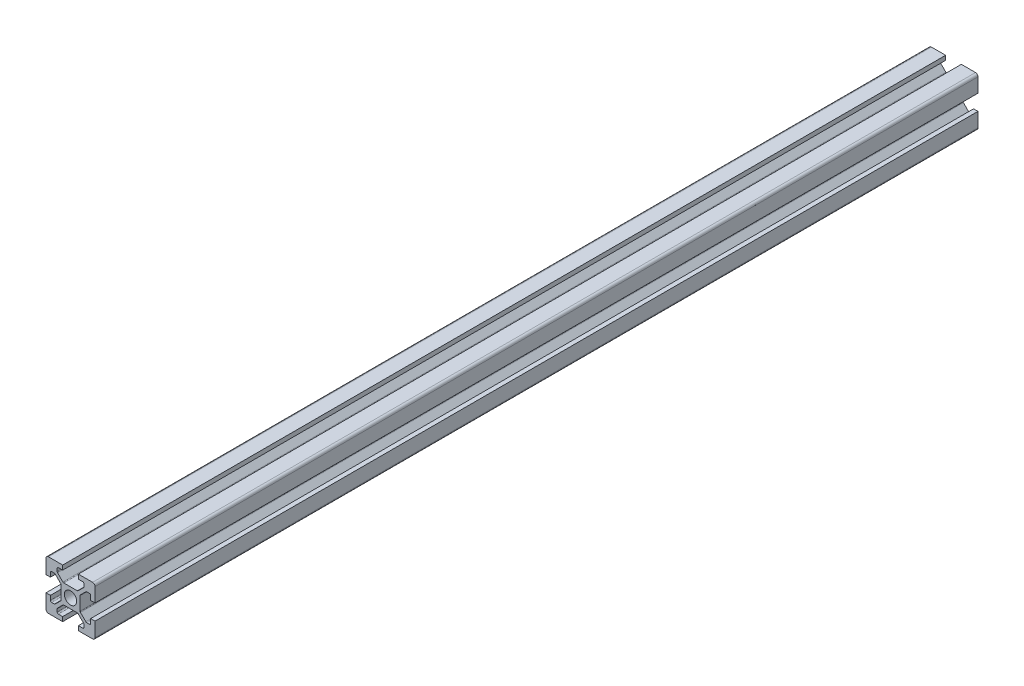
from build123d import *

# Parameters (mm, degrees)
SKETCH1_R           = 2.5
BOSS_EXTRUDE1_DEPTH = 360
FILLET1_R           = 1
FILLET2_R           = 0.5
FILLET3_R           = 0.5
FILLET4_R           = 0.5
FILLET5_R           = 0.5


with BuildPart() as part:
    # Sketch1 → Boss-Extrude1 (new body)
    with BuildSketch(Plane.XY):
        Polygon((13.2, 0), (13.2, 1.8), (15.45, 1.8), (15.45, 3.6), (12.95, 6.1), (7.05, 6.1), (4.55, 3.6), (4.55, 1.8), (6.8, 1.8), (6.8, 0), (0, 0), (0, 6.8), (1.8, 6.8), (1.8, 4.55), (3.6, 4.55), (6.1, 7.05), (6.1, 12.95), (3.6, 15.45), (1.8, 15.45), (1.8, 13.2), (0, 13.2), (0, 20), (6.8, 20), (6.8, 18.2), (4.55, 18.2), (4.55, 16.4), (7.05, 13.9), (12.95, 13.9), (15.45, 16.4), (15.45, 18.2), (13.2, 18.2), (13.2, 20), (20, 20), (20, 13.2), (18.2, 13.2), (18.2, 15.45), (16.4, 15.45), (13.9, 12.95), (13.9, 7.05), (16.4, 4.55), (18.2, 4.55), (18.2, 6.8), (20, 6.8), (20, 0), align=None)
        with Locations((10, 10)):
            Circle(SKETCH1_R, mode=Mode.SUBTRACT)
    extrude(amount=BOSS_EXTRUDE1_DEPTH)

    # Fillet1
    fillet1_edges = [part.edges().sort_by_distance(p)[0] for p in [
        (0, 0, 180),
        (0, 20, 180),
        (20, 20, 180),
        (20, 0, 180),
    ]]
    fillet(fillet1_edges, radius=FILLET1_R)

    # Fillet2
    fillet2_edges = [part.edges().sort_by_distance(p)[0] for p in [
        (4.55, 18.2, 180),
        (4.55, 16.4, 180),
        (7.05, 13.9, 180),
        (12.95, 13.9, 180),
        (15.45, 16.4, 180),
        (15.45, 18.2, 180),
    ]]
    fillet(fillet2_edges, radius=FILLET2_R)

    # Fillet3
    fillet3_edges = [part.edges().sort_by_distance(p)[0] for p in [
        (18.2, 15.45, 180),
        (16.4, 15.45, 180),
        (13.9, 12.95, 180),
        (13.9, 7.05, 180),
        (16.4, 4.55, 180),
        (18.2, 4.55, 180),
    ]]
    fillet(fillet3_edges, radius=FILLET3_R)

    # Fillet4
    fillet4_edges = [part.edges().sort_by_distance(p)[0] for p in [
        (1.8, 4.55, 180),
        (3.6, 4.55, 180),
        (6.1, 7.05, 180),
        (6.1, 12.95, 180),
        (3.6, 15.45, 180),
        (1.8, 15.45, 180),
    ]]
    fillet(fillet4_edges, radius=FILLET4_R)

    # Fillet5
    fillet5_edges = [part.edges().sort_by_distance(p)[0] for p in [
        (15.45, 1.8, 180),
        (15.45, 3.6, 180),
        (12.95, 6.1, 180),
        (7.05, 6.1, 180),
        (4.55, 3.6, 180),
        (4.55, 1.8, 180),
    ]]
    fillet(fillet5_edges, radius=FILLET5_R)


solid = part.part
